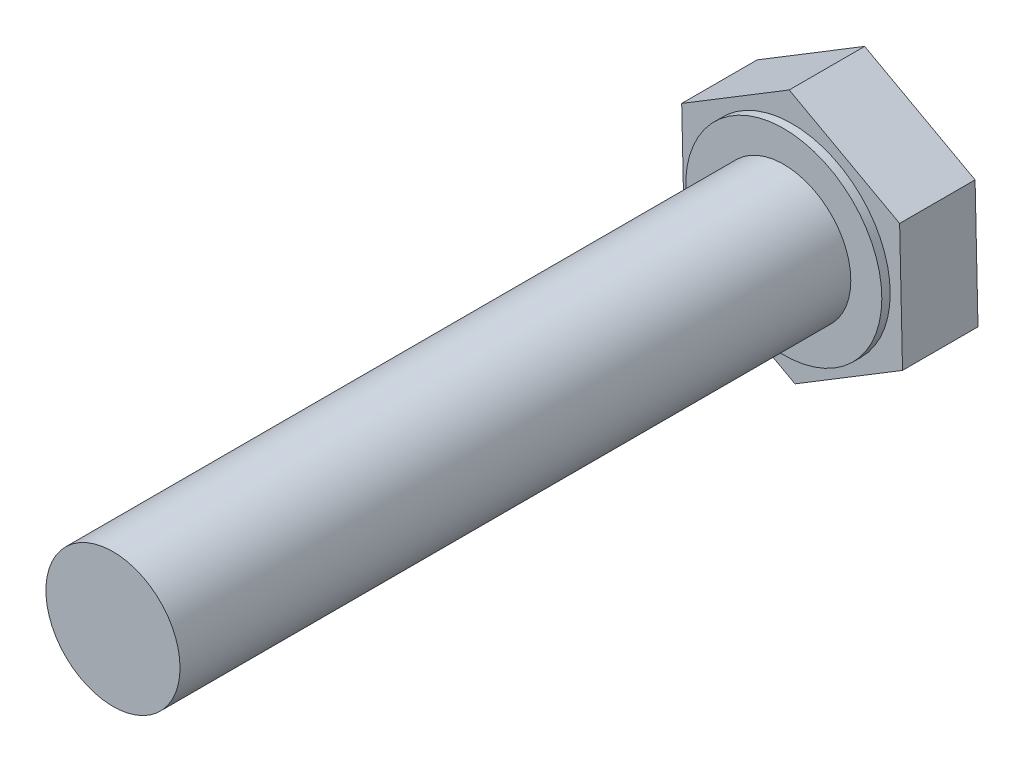
from build123d import *

# Parameters (mm, degrees)
BOSS_EXTRUDE1_DEPTH = 4.5
SKETCH2_R           = 5.85
BOSS_EXTRUDE2_DEPTH = 0.5
SKETCH3_R           = 4
BOSS_EXTRUDE3_DEPTH = 40


with BuildPart() as part:
    # Sketch1 → Boss-Extrude1 (new body)
    with BuildSketch(Plane.XY):
        Polygon((-6.411545587, -3.901975976), (0.173437527, -7.503549344), (6.584983114, -3.601573368), (6.411545587, 3.901975976), (-0.173437527, 7.503549344), (-6.584983114, 3.601573368), align=None)
    extrude(amount=BOSS_EXTRUDE1_DEPTH)

    # Sketch2 → Boss-Extrude2 (add)
    with BuildSketch(Plane.XY.offset(4.5)):
        Circle(SKETCH2_R)
    extrude(amount=BOSS_EXTRUDE2_DEPTH)

    # Sketch3 → Boss-Extrude3 (add)
    with BuildSketch(Plane.XY.offset(5)):
        Circle(SKETCH3_R)
    extrude(amount=BOSS_EXTRUDE3_DEPTH)


solid = part.part
